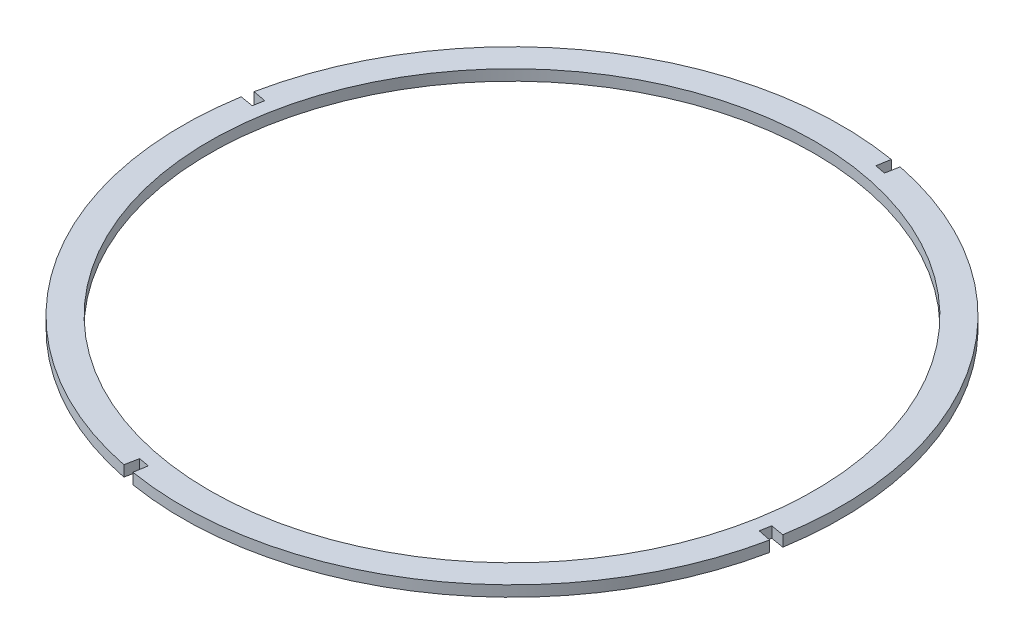
from build123d import *

# Parameters (mm, degrees)
SKETCH_1_R      = 448.7
EXTRUDE_2_DEPTH = 16


with BuildPart() as part:
    # Эскиз1 → Бобышка-Вытянуть2 (new body)
    with BuildSketch(Plane(origin=(0, 0, 0), x_dir=(1, 0, 0), z_dir=(0, 1, 0))):
        with BuildLine():
            Line((-344.32913914, 638.733962842), (-328.594635558, 635.831309398))
            Line((-328.594635558, 635.831309398), (-324.978198629, 655.435041258))
            ThreePointArc((-324.978198629, 655.435041258), (-19.068388145, 453.638466212), (60.542297577, 95.916774711))
            Line((60.542297577, 95.916774711), (40.882449344, 99.197669255))
            Line((40.882449344, 99.197669255), (37.979795899, 83.463165673))
            Line((37.979795899, 83.463165673), (57.516225139, 79.513249965))
            ThreePointArc((57.516225139, 79.513249965), (-144.23681545, -226.079457497), (-501.65610266, -305.720184329))
            Line((-501.65610266, -305.720184329), (-498.386954822, -286.060743027))
            Line((-498.386954822, -286.060743027), (-514.12229676, -283.162637766))
            Line((-514.12229676, -283.162637766), (-518.061372416, -302.703594153))
            ThreePointArc((-518.061372416, -302.703594153), (-823.9309706, -100.894655009), (-903.52528096, 256.803268902))
            Line((-903.52528096, 256.803268902), (-883.865432727, 253.522374358))
            Line((-883.865432727, 253.522374358), (-880.962779283, 269.256877941))
            Line((-880.962779283, 269.256877941), (-900.566511143, 272.873314869))
            ThreePointArc((-900.566511143, 272.873314869), (-698.769936097, 578.783125354), (-341.048244596, 658.393811076))
            Line((-341.048244596, 658.393811076), (-344.32913914, 638.733962842))
        make_face()
        with Locations((-421.491491692, 176.360021807)):
            Circle(SKETCH_1_R, mode=Mode.SUBTRACT)
    extrude(amount=EXTRUDE_2_DEPTH)


solid = part.part
